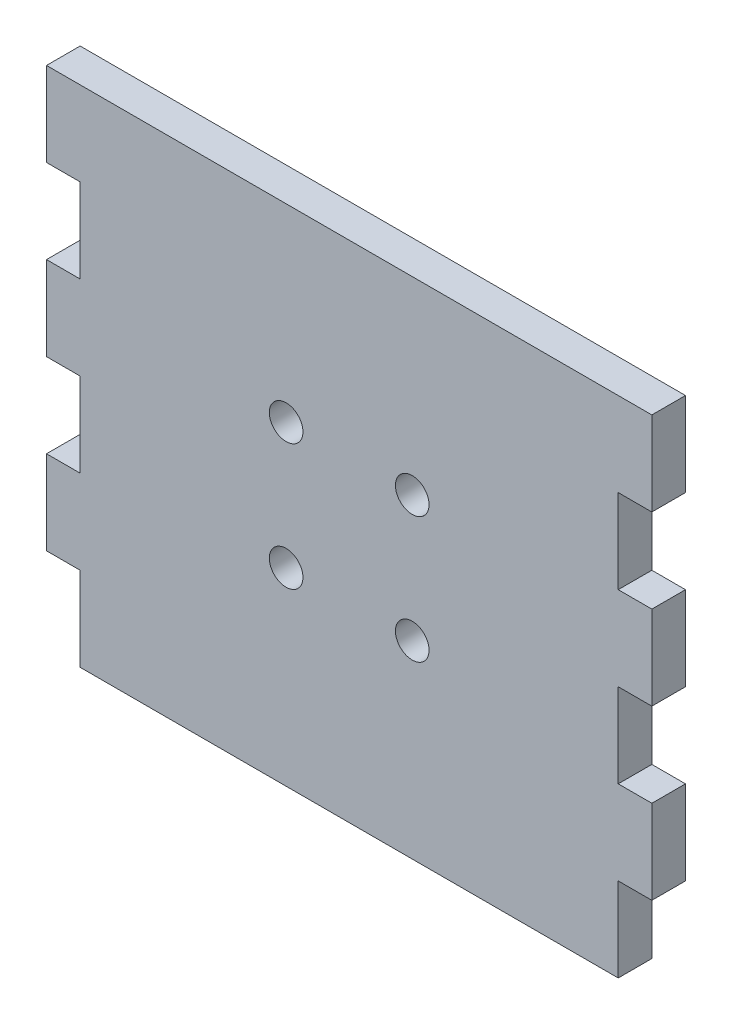
from build123d import *

# Parameters (mm, degrees)
SKETCH1_R           = 2
BOSS_EXTRUDE1_DEPTH = 4


with BuildPart() as part:
    # Sketch1 → Boss-Extrude1 (new body)
    with BuildSketch(Plane.XY):
        Polygon((36, 20), (32, 20), (32, 10), (36, 10), (36, 0), (32, 0), (32, -10), (36, -10), (36, -20), (32, -20), (32, -30), (-32, -30), (-32, -20), (-36, -20), (-36, -10), (-32, -10), (-32, 0), (-36, 0), (-36, 10), (-32, 10), (-32, 20), (-36, 20), (-36, 30), (36, 30), align=None)
        with Locations((-7.5, 7.5)):
            Circle(SKETCH1_R, mode=Mode.SUBTRACT)
        with Locations((-7.5, -7.5)):
            Circle(SKETCH1_R, mode=Mode.SUBTRACT)
        with Locations((7.5, -7.5)):
            Circle(SKETCH1_R, mode=Mode.SUBTRACT)
        with Locations((7.5, 7.5)):
            Circle(SKETCH1_R, mode=Mode.SUBTRACT)
    extrude(amount=BOSS_EXTRUDE1_DEPTH)


solid = part.part
